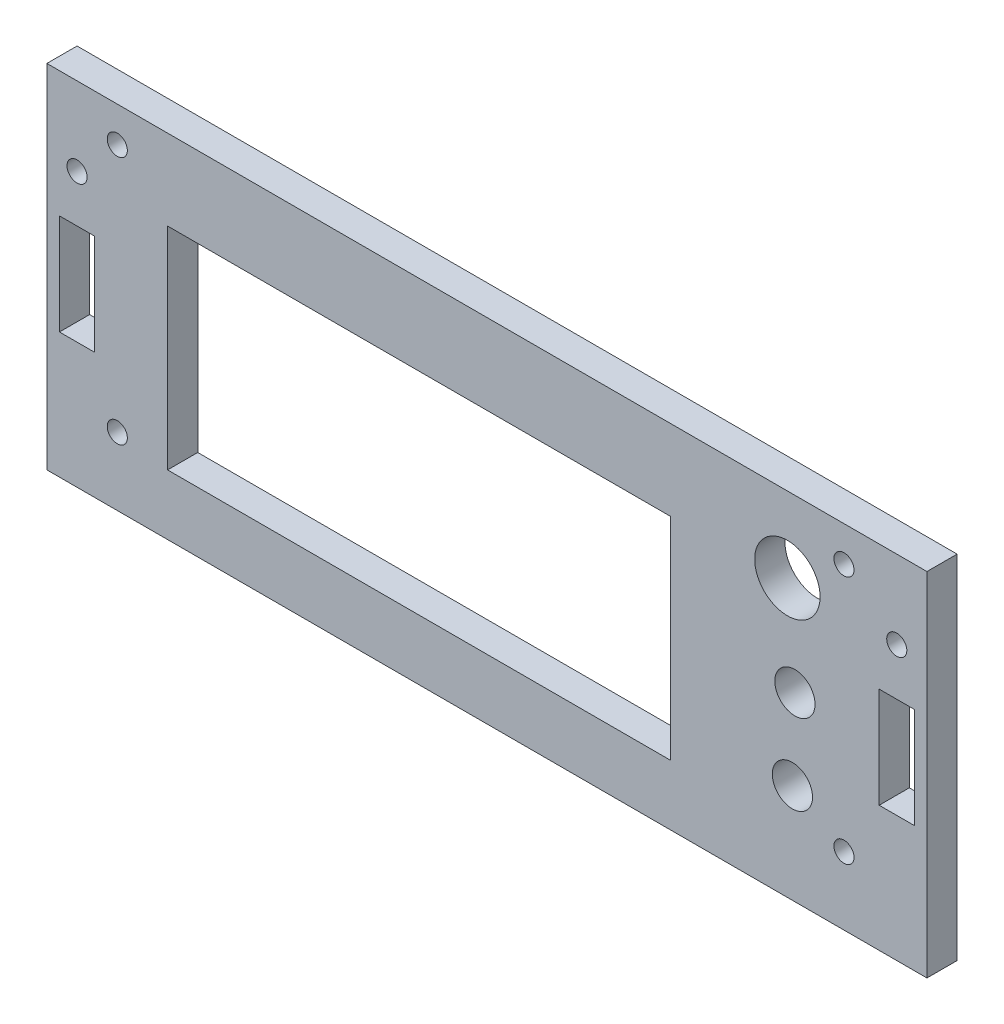
from build123d import *

# Parameters (mm, degrees)
ESQUISSE1_W             = 175
ESQUISSE1_H             = 70
ESQUISSE1_W_2           = 100
ESQUISSE1_H_2           = 42
BOSS_EXTRU_1_DEPTH      = 6
ESQUISSE2_R             = 2
ESQUISSE2_W             = 7
ESQUISSE2_H             = 20
ENL_V_MAT_EXTRU_1_DEPTH = 6
ESQUISSE3_R             = 2
ESQUISSE3_R_2           = 6.5
ESQUISSE3_R_3           = 4
ENL_V_MAT_EXTRU_2_DEPTH = 6


with BuildPart() as part:
    # Esquisse1 → Boss.-Extru.1 (new body)
    with BuildSketch(Plane.XY):
        Rectangle(ESQUISSE1_W, ESQUISSE1_H)
        with Locations((-13.5, -2)):
            Rectangle(ESQUISSE1_W_2, ESQUISSE1_H_2, mode=Mode.SUBTRACT)
    extrude(amount=BOSS_EXTRU_1_DEPTH)

    # Esquisse2 → Enlèv. mat.-Extru.1 (cut)
    with BuildSketch(Plane.XY.offset(6)):
        with Locations((-81.5, 19.4)):
            Circle(ESQUISSE2_R)
        with Locations((-81.5, 0)):
            Rectangle(ESQUISSE2_W, ESQUISSE2_H)
    enl_v_mat_extru_1 = extrude(amount=-ENL_V_MAT_EXTRU_1_DEPTH, mode=Mode.SUBTRACT)

    # Symétrie1: Enlèv. mat.-Extru.1 across plane
    add(enl_v_mat_extru_1.mirror(Plane(origin=(0, 0, 0), x_dir=(0, 0, 1), z_dir=(1, 0, 0))), mode=Mode.SUBTRACT)

    # Esquisse3 → Enlèv. mat.-Extru.2 (cut)
    with BuildSketch(Plane.XY.offset(6)):
        with Locations((-73.5, 28)):
            Circle(ESQUISSE3_R)
        with Locations((71, 28)):
            Circle(ESQUISSE3_R)
        with Locations((71, -21.5)):
            Circle(ESQUISSE3_R)
        with Locations((-73.5, -21.5)):
            Circle(ESQUISSE3_R)
        with Locations((59.75, 20)):
            Circle(ESQUISSE3_R_2)
        with Locations((61.25, 1)):
            Circle(ESQUISSE3_R_3)
        with Locations((60.75, -15.25)):
            Circle(ESQUISSE3_R_3)
    extrude(amount=-ENL_V_MAT_EXTRU_2_DEPTH, mode=Mode.SUBTRACT)


solid = part.part
